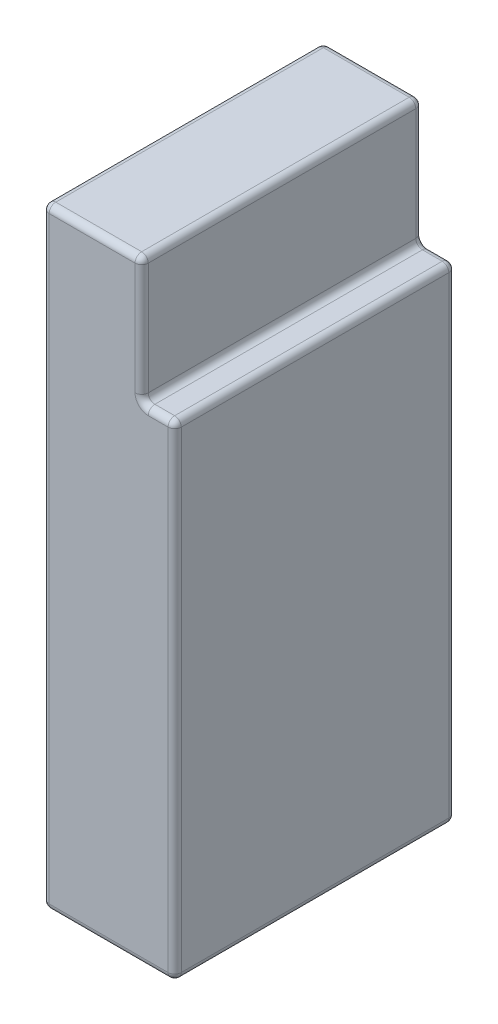
from build123d import *

# Parameters (mm, degrees)
SKETCH_1_W          = 20
SKETCH_1_H          = 42.5
EXTRUDE_1_DEPTH     = 92.5
SKETCH_3_W          = 42.5
SKETCH_3_H          = 19
CUT_EXTRUDE_1_DEPTH = 5
FILLET_1_R          = 1


with BuildPart() as part:
    # 草图1 → 凸台-拉伸1 (new body)
    with BuildSketch(Plane(origin=(0, 0, 0), x_dir=(1, 0, 0), z_dir=(0, 1, 0))):
        Rectangle(SKETCH_1_W, SKETCH_1_H)
    extrude(amount=EXTRUDE_1_DEPTH)

    # 草图3 → 切除-拉伸1 (cut)
    with BuildSketch(Plane(origin=(10, 0, 0), x_dir=(0, 0, -1), z_dir=(1, 0, 0))):
        with Locations((0, 83)):
            Rectangle(SKETCH_3_W, SKETCH_3_H)
    extrude(amount=-CUT_EXTRUDE_1_DEPTH, mode=Mode.SUBTRACT)

    # 圆角1
    fillet_1_edges = [part.edges().sort_by_distance(p)[0] for p in [
        (-10, 92.5, 0),
        (-2.5, 92.5, -21.25),
        (10, 36.75, 21.25),
        (-2.5, 92.5, 21.25),
        (10, 36.75, -21.25),
        (5, 83, 21.25),
        (7.5, 73.5, 21.25),
        (5, 92.5, 0),
        (5, 83, -21.25),
        (5, 73.5, 0),
        (7.5, 73.5, -21.25),
        (10, 73.5, 0),
        (0, 0, 21.25),
        (-10, 0, 0),
        (0, 0, -21.25),
        (10, 0, 0),
        (-10, 46.25, 21.25),
        (-10, 46.25, -21.25),
    ]]
    fillet(fillet_1_edges, radius=FILLET_1_R)


solid = part.part
